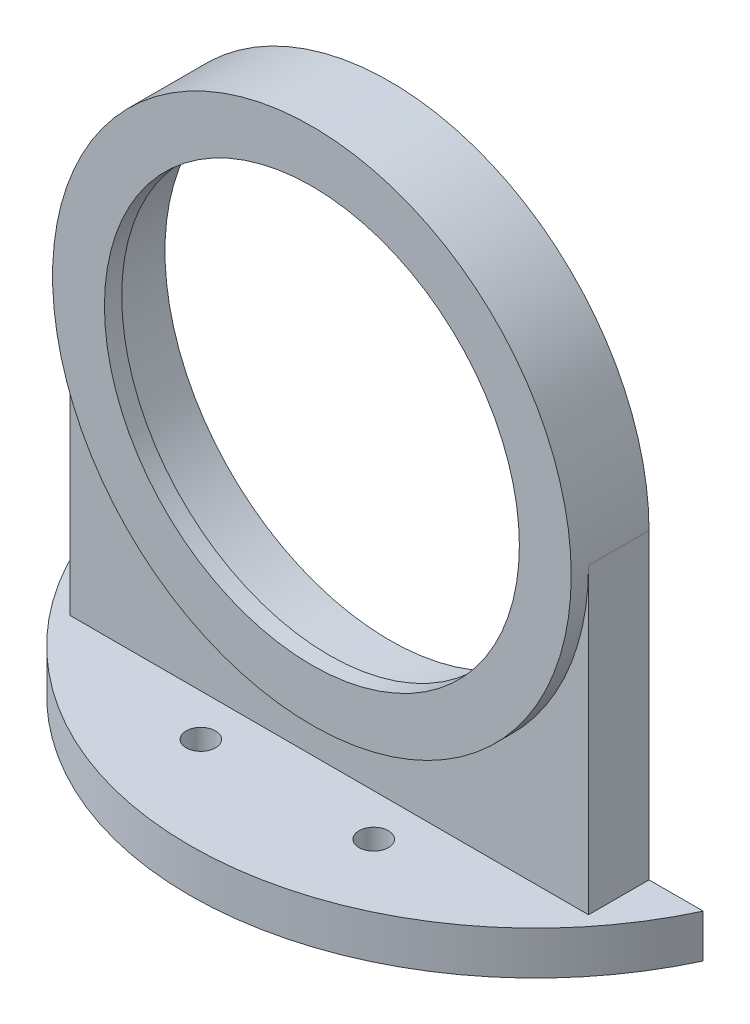
from build123d import *

# Parameters (mm, degrees)
SKETCH_1_R          = 26
EXTRUDE_1_DEPTH     = 7
EXTRUDE_3_DEPTH     = 5
SKETCH_4_R          = 30
SKETCH_4_R_2        = 24
EXTRUDE_4_DEPTH     = 2
EXTRUDE_5_DEPTH     = 7
EXTRUDE_6_DEPTH     = 2
CUT_EXTRUDE_2_DEPTH = 2
SKETCH_11_R         = 1.7
CUT_EXTRUDE_3_DEPTH = 10


with BuildPart() as part:
    # 草图1 → 凸台-拉伸1 (new body)
    with BuildSketch(Plane.XY):
        with BuildLine():
            Line((-15.5, -38), (15.5, -38))
            Line((15.5, -38), (15.5, -25.685599078))
            ThreePointArc((15.5, -25.685599078), (0, 30), (-15.5, -25.685599078))
            Line((-15.5, -25.685599078), (-15.5, -38))
        make_face()
        Circle(SKETCH_1_R, mode=Mode.SUBTRACT)
    extrude(amount=EXTRUDE_1_DEPTH)

    # 草图3 → 凸台-拉伸3 (add)
    with BuildSketch(Plane.XZ.offset(38)):
        with BuildLine():
            Line((-36.263833223, 0), (36.263833223, 0))
            ThreePointArc((36.263833223, 0), (0, 23.12), (-36.263833223, 0))
        make_face()
    extrude(amount=-EXTRUDE_3_DEPTH)

    # 草图4 → 凸台-拉伸4 (add)
    with BuildSketch(Plane.XY.offset(7)):
        Circle(SKETCH_4_R)
        Circle(SKETCH_4_R_2, mode=Mode.SUBTRACT)
    extrude(amount=EXTRUDE_4_DEPTH)

    # 草图5 → 凸台-拉伸5 (add)
    with BuildSketch(Plane(origin=(0, 0, 0), x_dir=(-1, 0, 0), z_dir=(0, 0, -1))):
        with BuildLine():
            Line((-30, -33), (-15.5, -33))
            Line((-15.5, -33), (-15.5, -25.685599078))
            ThreePointArc((-15.5, -25.685599078), (-26.124700955, -14.747881204), (-30, 0))
            Line((-30, 0), (-30, -33))
        make_face()
        with BuildLine():
            Line((15.5, -33), (15.5, -25.685599078))
            ThreePointArc((15.5, -25.685599078), (26.124700955, -14.747881204), (30, 0))
            Line((30, 0), (30, -33))
            Line((30, -33), (15.5, -33))
        make_face()
    extrude(amount=-EXTRUDE_5_DEPTH)

    # 草图8 → 凸台-拉伸6 (add)
    with BuildSketch(Plane.XZ.offset(38)):
        with BuildLine():
            Line((-36.263833223, 0), (36.263833223, 0))
            ThreePointArc((36.263833223, 0), (0, 23.12), (-36.263833223, 0))
        make_face()
    extrude(amount=EXTRUDE_6_DEPTH)

    # 草图9 → 切除-拉伸2 (cut)
    with BuildSketch(Plane(origin=(0, -33, 0), x_dir=(1, 0, 0), z_dir=(0, 1, 0))):
        with BuildLine():
            Line((30, -7), (-30, -7))
            Line((-30, -7), (-30, 0))
            Line((-30, 0), (-36.263833223, 0))
            ThreePointArc((-36.263833223, 0), (0, -23.12), (36.263833223, 0))
            Line((36.263833223, 0), (30, 0))
            Line((30, 0), (30, -7))
        make_face()
    extrude(amount=-CUT_EXTRUDE_2_DEPTH, mode=Mode.SUBTRACT)

    # 草图11 → 切除-拉伸3 (cut)
    with BuildSketch(Plane(origin=(0, -35, 0), x_dir=(1, 0, 0), z_dir=(0, 1, 0))):
        with Locations((-10, -11.85)):
            Circle(SKETCH_11_R)
        with Locations((10, -11.85)):
            Circle(SKETCH_11_R)
    extrude(amount=-CUT_EXTRUDE_3_DEPTH, mode=Mode.SUBTRACT)


solid = part.part
